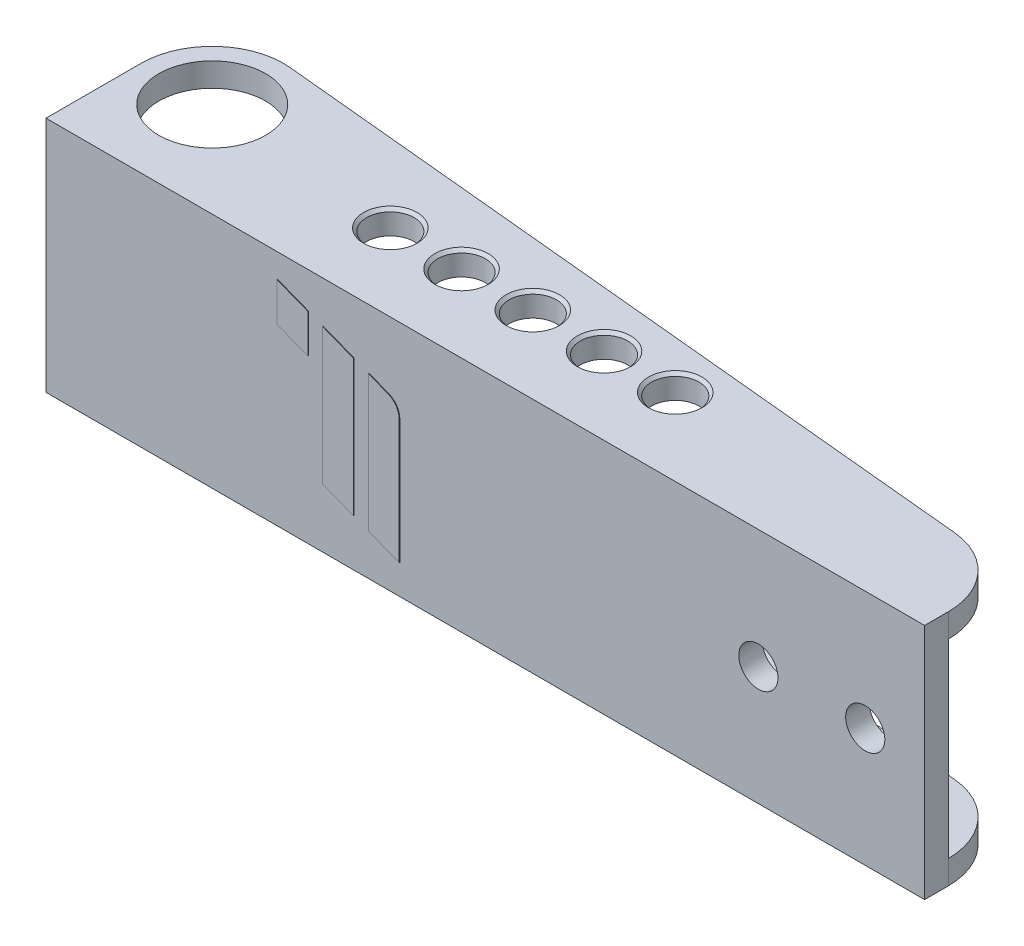
from build123d import *

# Parameters (mm, degrees)
ESQUISSE1_W             = 148
ESQUISSE1_H             = 40
BOSS_EXTRU_1_DEPTH      = 30
ESQUISSE2_OUTSIDE_W     = 181.244
ESQUISSE2_OUTSIDE_H     = 63.244
ENL_V_MAT_EXTRU_1_DEPTH = 41
ESQUISSE3_W             = 24
ESQUISSE3_H             = 32
ENL_V_MAT_EXTRU_3_DEPTH = 149
ESQUISSE4_R             = 9
ESQUISSE4_R_2           = 4
ENL_V_MAT_EXTRU_4_DEPTH = 41
CHANFREIN1_SIZE         = 0.5
D_GAGEMENT_M61_D        = 6.6
BOSS_EXTRU_2_DEPTH      = 0.1


with BuildPart() as part:
    # Esquisse1 → Boss.-Extru.1 (new body)
    with BuildSketch(Plane.XY):
        Rectangle(ESQUISSE1_W, ESQUISSE1_H)
    extrude(amount=BOSS_EXTRU_1_DEPTH)

    # Esquisse2 outside → Enlèv. mat.-Extru.1 (cut, through all)
    with BuildSketch(Plane(origin=(0, 20, 0), x_dir=(1, 0, 0), z_dir=(0, 1, 0))):
        with Locations((0, -15)):
            Rectangle(ESQUISSE2_OUTSIDE_W, ESQUISSE2_OUTSIDE_H)
        with BuildLine():
            Line((-74, -14), (-74, -30))
            Line((-74, -30), (74, -30))
            Line((74, -30), (74, -26))
            ThreePointArc((74, -26), (70.853760815, -17.858682375), (63.050333897, -13.948899514))
            Line((63.050333897, -13.948899514), (-60.853344924, -2.054909706))
            ThreePointArc((-60.853344924, -2.054909706), (-70.06970071, -5.118562591), (-74, -14))
        make_face(mode=Mode.SUBTRACT)
    extrude(amount=-ENL_V_MAT_EXTRU_1_DEPTH, mode=Mode.SUBTRACT)

    # Esquisse3 → Enlèv. mat.-Extru.3 (cut, through all)
    with BuildSketch(Plane.ZY.offset(74)):
        with Locations((14, 0)):
            Rectangle(ESQUISSE3_W, ESQUISSE3_H)
    extrude(amount=-ENL_V_MAT_EXTRU_3_DEPTH, mode=Mode.SUBTRACT)

    # Esquisse4 → Enlèv. mat.-Extru.4 (cut, through all)
    with BuildSketch(Plane(origin=(0, 20, 0), x_dir=(1, 0, 0), z_dir=(0, 1, 0))):
        with Locations((-62, -14)):
            Circle(ESQUISSE4_R)
        with Locations((-29, -17)):
            Circle(ESQUISSE4_R_2)
        with Locations((-17, -17)):
            Circle(ESQUISSE4_R_2)
        with Locations((-5, -17)):
            Circle(ESQUISSE4_R_2)
        with Locations((7, -17)):
            Circle(ESQUISSE4_R_2)
        with Locations((19, -17)):
            Circle(ESQUISSE4_R_2)
    extrude(amount=-ENL_V_MAT_EXTRU_4_DEPTH, mode=Mode.SUBTRACT)

    # Chanfrein1
    chanfrein1_edges = [part.edges().sort_by_distance(p)[0] for p in [
        (3, 20, 17),
        (15, -20, 17),
        (15, 20, 17),
        (-33, -20, 17),
        (-33, 20, 17),
        (-21, -20, 17),
        (-21, 20, 17),
        (-9, -20, 17),
        (-9, 20, 17),
        (3, -20, 17),
    ]]
    chamfer(chanfrein1_edges, length=CHANFREIN1_SIZE)

    # Dégagement M61 (through all)
    with Locations(Plane.XY.offset(30)):
        with Locations((46, 0), (64, 0)):
            Hole(D_GAGEMENT_M61_D / 2)

    # Esquisse9 → Boss.-Extru.2 (add)
    with BuildSketch(Plane.XY.offset(30)):
        Polygon((-35, 16), (-35, 9.5), (-29.8, 7.474025974), (-29.8, 13.974025974), align=None)
        Polygon((-27.3, 13), (-27.3, -9.974025974), (-22.1, -12), (-22.1, 10.974025974), align=None)
        with BuildLine():
            Line((-19.6, 10), (-19.6, -12.974025974))
            Line((-19.6, -12.974025974), (-14.4, -15))
            Line((-14.4, -15), (-14.4, 5.923204009))
            ThreePointArc((-14.4, 5.923204009), (-14.923382208, 7.616238065), (-16.310909542, 8.718536185))
            Line((-16.310909542, 8.718536185), (-19.6, 10))
        make_face()
    extrude(amount=BOSS_EXTRU_2_DEPTH)


solid = part.part
